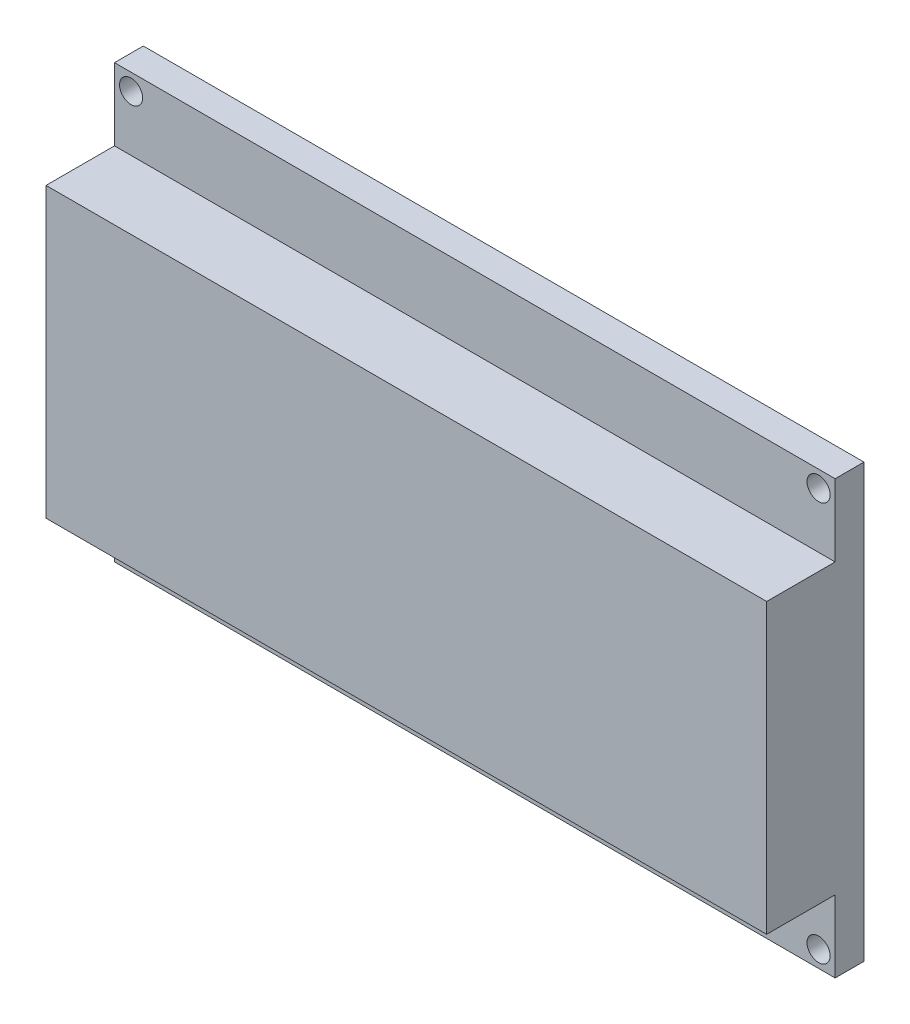
from build123d import *

# Parameters (mm, degrees)
ESQUISSE1_W        = 100
ESQUISSE1_H        = 60
ESQUISSE1_R        = 1.6
BOSS_EXTRU_1_DEPTH = 4
ESQUISSE2_W        = 100
ESQUISSE2_H        = 40
BOSS_EXTRU_2_DEPTH = 9.5


with BuildPart() as part:
    # Esquisse1 → Boss.-Extru.1 (new body)
    with BuildSketch(Plane.XY):
        with Locations((50, 30)):
            Rectangle(ESQUISSE1_W, ESQUISSE1_H)
        with Locations((2.3, 57.7)):
            Circle(ESQUISSE1_R, mode=Mode.SUBTRACT)
        with Locations((97.7, 57.7)):
            Circle(ESQUISSE1_R, mode=Mode.SUBTRACT)
        with Locations((97.7, 2.3)):
            Circle(ESQUISSE1_R, mode=Mode.SUBTRACT)
        with Locations((2.3, 2.3)):
            Circle(ESQUISSE1_R, mode=Mode.SUBTRACT)
    extrude(amount=BOSS_EXTRU_1_DEPTH)

    # Esquisse2 → Boss.-Extru.2 (add)
    with BuildSketch(Plane.XY.offset(4)):
        with Locations((50, 30)):
            Rectangle(ESQUISSE2_W, ESQUISSE2_H)
    extrude(amount=BOSS_EXTRU_2_DEPTH)


solid = part.part
